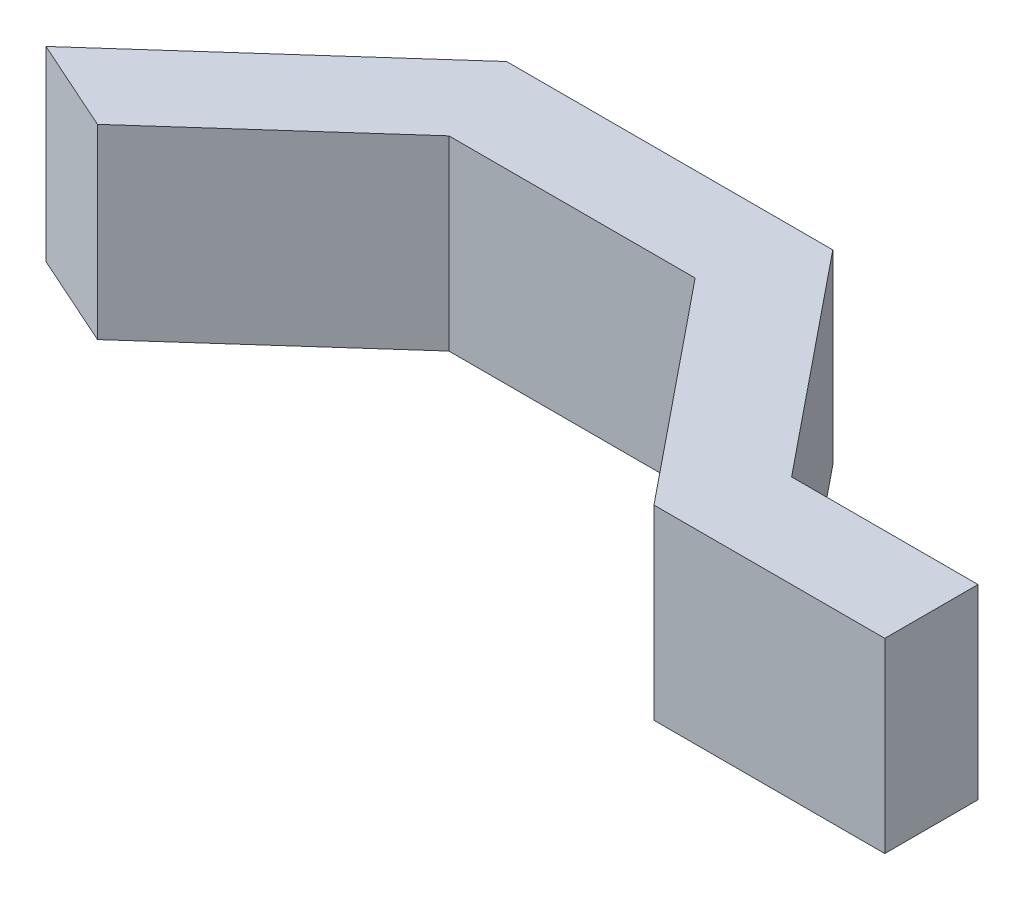
from build123d import *

# Parameters (mm, degrees)
BOSS_EXTRUDE1_DEPTH      = 10
BOSS_EXTRUDE1_DEPTH_BACK = 10
SKETCH2_R                = 2.5
CUT_EXTRUDE1_DEPTH       = 4
SPLIT2_SURFACE_1_BACK    = 108.282
SPLIT2_SURFACE_1_DEPTH   = 216.564


with BuildPart() as part:
    # Sketch1 → Boss-Extrude1 (new, two sides)
    with BuildSketch(Plane(origin=(0, 0, 0), x_dir=(1, 0, 0), z_dir=(0, 1, 0))) as boss_extrude1_sk:
        Polygon((-51.374196063, 7.601926758), (-51.374196063, -2.398073242), (-41.374196063, -2.398073242), (-41.374196063, 3.123704189), (-21.449234595, 20.908790051), (4.969602102, 20.908790051), (23.858490991, -2.398073242), (48.625803937, -2.398073242), (48.625803937, 7.601926758), (28.625803937, 7.601926758), (9.736915048, 30.908790051), (-25.263084952, 30.908790051), align=None)
    extrude(amount=BOSS_EXTRUDE1_DEPTH)
    extrude(boss_extrude1_sk.sketch, amount=-BOSS_EXTRUDE1_DEPTH_BACK)

    # Sketch2 → Cut-Extrude1 (cut)
    with BuildSketch(Plane.XZ.offset(10)):
        with Locations(Location((45.625803937, -2.601926758, 0), (0, 0, 270))):
            Circle(SKETCH2_R)
    extrude(amount=-CUT_EXTRUDE1_DEPTH, mode=Mode.SUBTRACT)

    # Split2: cut with a surface, the side it looks to stays
    # Split2 surface: a surface, the sketch's curves swept straight by 216.564 mm
    with BuildLine(Plane(origin=(0, 10, 0), x_dir=(1, 0, 0), z_dir=(0, 1, 0)).offset(-SPLIT2_SURFACE_1_BACK), mode=Mode.PRIVATE) as split2_surface_1_path:
        Line((-51.374196063, 7.601926758), (-41.374196063, 3.123704189))
    split2_surface_1 = Shell.extrude(split2_surface_1_path.wire(), (0 * SPLIT2_SURFACE_1_DEPTH, 1 * SPLIT2_SURFACE_1_DEPTH, 0 * SPLIT2_SURFACE_1_DEPTH))
    split(bisect_by=split2_surface_1, keep=Keep.TOP)


solid = part.part
